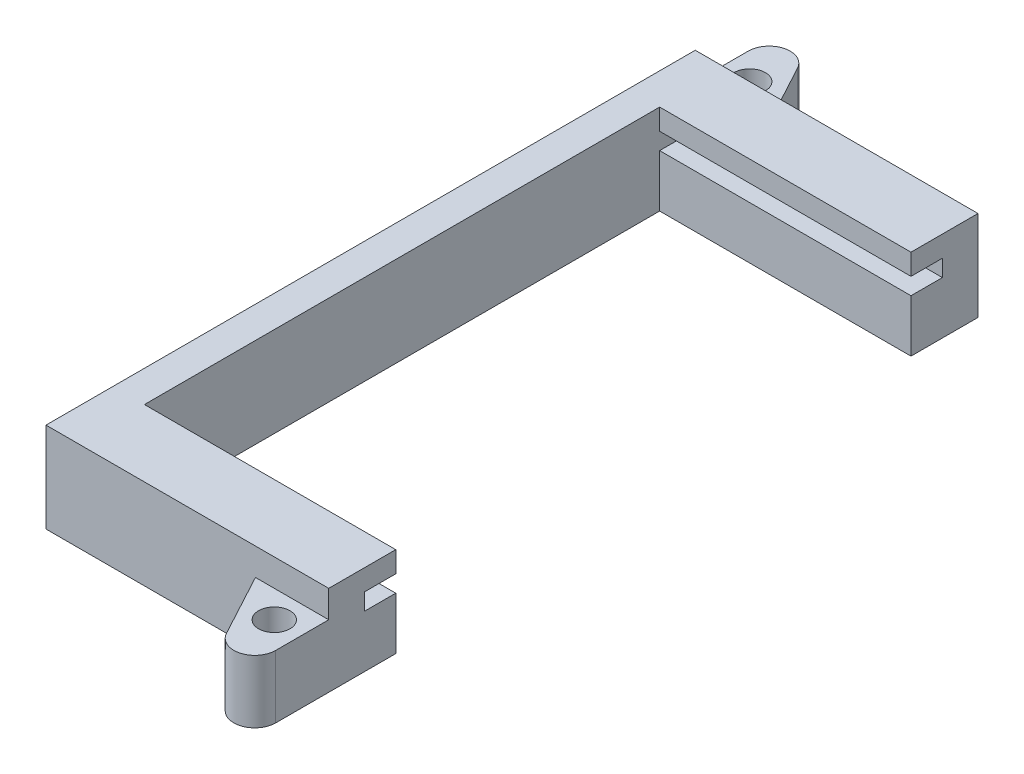
from build123d import *

# Parameters (mm, degrees)
BOSS_EXTRUDE1_DEPTH = 30.48
SKETCH2_W           = 3.81
SKETCH2_H           = 10.922
BOSS_EXTRUDE2_DEPTH = 78.74
BOSS_EXTRUDE3_DEPTH = 7.62
SKETCH5_R           = 1.905
CUT_EXTRUDE2_DEPTH  = 8.62
SKETCH6_W           = 30.48
SKETCH6_H           = 62.484
CUT_EXTRUDE3_DEPTH  = 7.35


with BuildPart() as part:
    # Sketch1 → Boss-Extrude1 (new body)
    with BuildSketch(Plane(origin=(0, 0, 0), x_dir=(0, 0, -1), z_dir=(1, 0, 0))):
        Polygon((0, 0), (78.74, 0), (78.74, 10.922), (70.612, 10.922), (70.612, 8.382), (74.422, 8.382), (74.422, 6.35), (4.318, 6.35), (4.318, 8.382), (8.128, 8.382), (8.128, 10.922), (0, 10.922), align=None)
    extrude(amount=BOSS_EXTRUDE1_DEPTH)

    # Sketch2 → Boss-Extrude2 (add)
    with BuildSketch(Plane.XY):
        with Locations((-1.905, 5.461)):
            Rectangle(SKETCH2_W, SKETCH2_H)
    extrude(amount=-BOSS_EXTRUDE2_DEPTH)

    # Sketch4 → Boss-Extrude3 (add)
    with BuildSketch(Plane.XZ):
        with BuildLine():
            Line((21.59, 0), (25.704138816, 7.632415502))
            ThreePointArc((25.704138816, 7.632415502), (28.56149521, 8.89), (30.48, 6.427208148))
            Line((30.48, 6.427208148), (30.48, 0))
            Line((30.48, 0), (21.59, 0))
        make_face()
        with BuildLine():
            Line((-3.81, -78.74), (-3.81, -85.167208148))
            ThreePointArc((-3.81, -85.167208148), (-1.89149521, -87.63), (0.965861184, -86.372415502))
            Line((0.965861184, -86.372415502), (5.08, -78.74))
            Line((5.08, -78.74), (-3.81, -78.74))
        make_face()
    extrude(amount=-BOSS_EXTRUDE3_DEPTH)

    # Sketch5 → Cut-Extrude2 (cut, through all)
    with BuildSketch(Plane(origin=(0, 7.62, 0), x_dir=(1, 0, 0), z_dir=(0, 1, 0))):
        with Locations((-0.508, 82.042)):
            Circle(SKETCH5_R)
        with Locations((27.178, -3.302)):
            Circle(SKETCH5_R)
    extrude(amount=-CUT_EXTRUDE2_DEPTH, mode=Mode.SUBTRACT)

    # Sketch6 → Cut-Extrude3 (cut, through all)
    with BuildSketch(Plane(origin=(0, 6.35, 0), x_dir=(1, 0, 0), z_dir=(0, 1, 0))):
        with Locations((15.24, 39.37)):
            Rectangle(SKETCH6_W, SKETCH6_H)
    extrude(amount=-CUT_EXTRUDE3_DEPTH, mode=Mode.SUBTRACT)


solid = part.part
